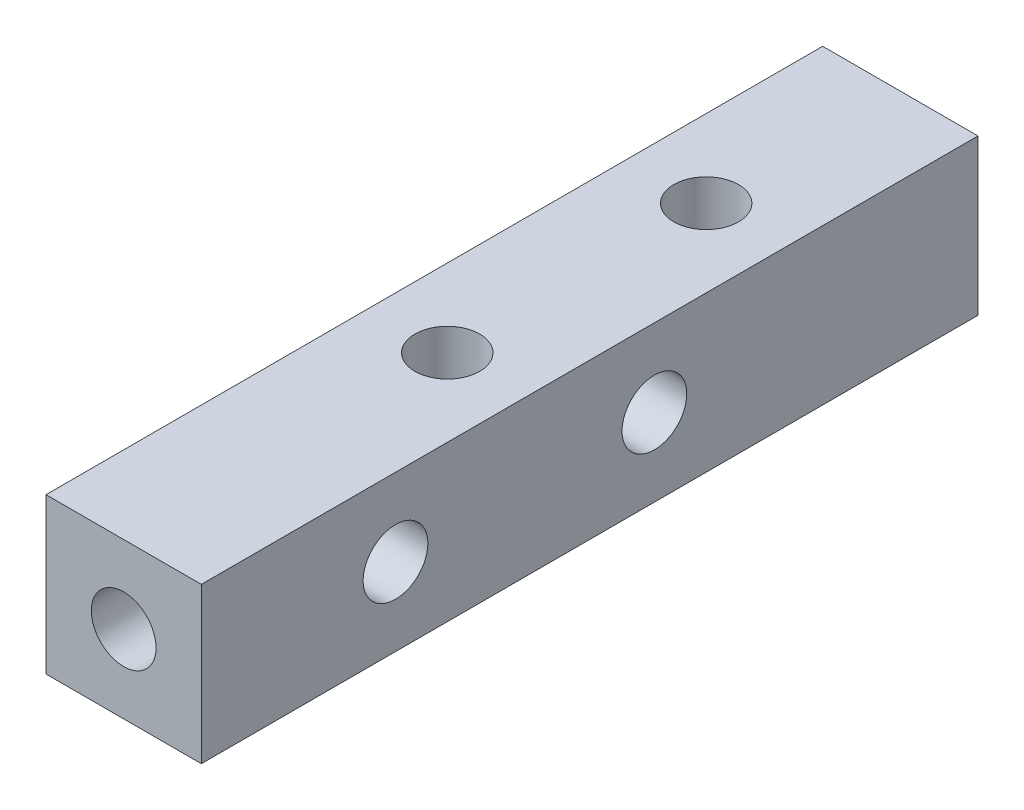
from build123d import *

# Parameters (mm, degrees)
SKETCH_1_W         = 30
SKETCH_1_H         = 6
EXTRUDE_1_DEPTH    = 6
HOLE_WIZARD_M3_1_D = 2.5
HOLE_WIZARD_M3_2_D = 2.5
HOLE_WIZARD_M3_3_D = 2.5


with BuildPart() as part:
    # 草图1 → 凸台-拉伸1 (new body)
    with BuildSketch(Plane(origin=(0, 0, 0), x_dir=(0, 0, -1), z_dir=(1, 0, 0))):
        with Locations((15, 3)):
            Rectangle(SKETCH_1_W, SKETCH_1_H)
    extrude(amount=EXTRUDE_1_DEPTH)

    # M3 螺纹孔1 (through all)
    with Locations(Plane.XY):
        with Locations((3, 3)):
            Hole(HOLE_WIZARD_M3_1_D / 2)

    # M3 螺纹孔2 (through all)
    with Locations(Plane(origin=(0, 6, 0), x_dir=(1, 0, 0), z_dir=(0, 1, 0))):
        with Locations((3, 12.5), (3, 22.5)):
            Hole(HOLE_WIZARD_M3_2_D / 2)

    # M3 螺纹孔3 (through all)
    with Locations(Plane(origin=(6, 0, 0), x_dir=(0, 0, -1), z_dir=(1, 0, 0))):
        with Locations((17.5, 3), (7.5, 3)):
            Hole(HOLE_WIZARD_M3_3_D / 2)


solid = part.part
